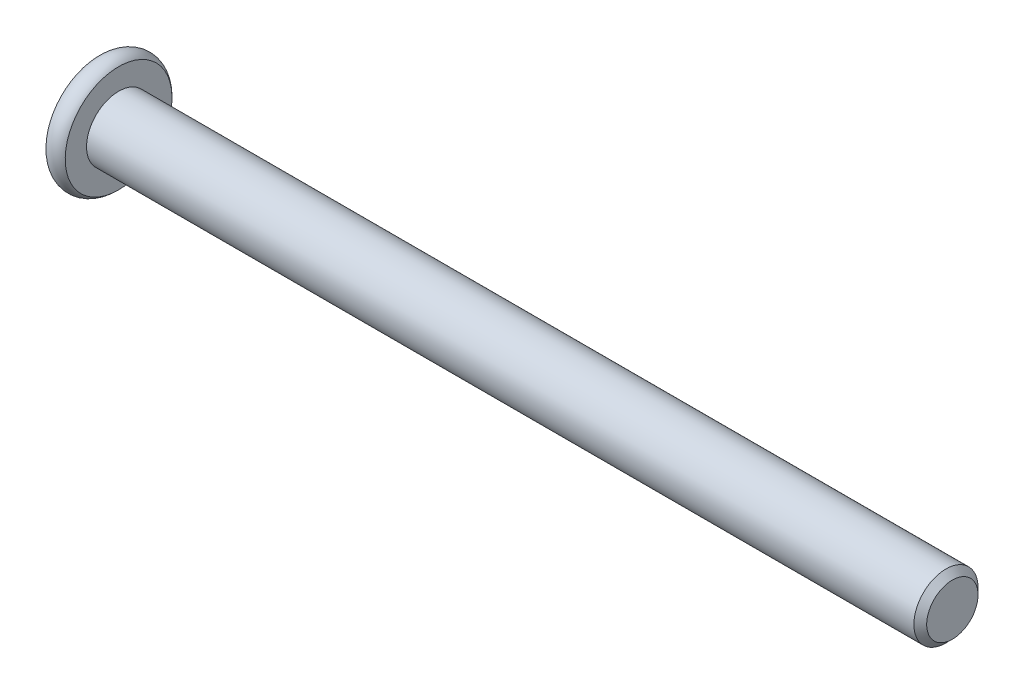
from build123d import *

# Parameters (mm, degrees)
SKETCH2_R           = 2.5
BOSS_EXTRUDE1_DEPTH = 65
CHAMFER1_SIZE       = 0.5
CUT_EXTRUDE1_DEPTH  = 2.3
SKETCH8_R           = 1.782050808
CUT_EXTRUDE2_DEPTH  = 1
CUT_EXTRUDE2_TAPER  = 45


with BuildPart() as part:
    # Sketch2 → Boss-Extrude1 (new body)
    with BuildSketch(Plane(origin=(0, 0, 0), x_dir=(0, 0, -1), z_dir=(1, 0, 0))):
        Circle(SKETCH2_R)
    extrude(amount=-BOSS_EXTRUDE1_DEPTH)

    # Chamfer1
    chamfer1_edges = [part.edges().sort_by_distance(p)[0] for p in [
        (0, 0, 2.5),
    ]]
    chamfer(chamfer1_edges, length=CHAMFER1_SIZE)

    # Sketch6 → Revolve1 (revolve)
    with BuildSketch(Plane.XY):
        with BuildLine():
            Line((-66.5, 0), (-66.5, 4.161437828))
            ThreePointArc((-66.5, 4.161437828), (-65.75, 4.5), (-65, 4.161437828))
            Line((-65, 4.161437828), (-65, 0))
            Line((-65, 0), (-66.5, 0))
        make_face()
    revolve(axis=Axis((-65, 0, 0), (1, 0, 0)))

    # Sketch7 → Cut-Extrude1 (cut)
    with BuildSketch(Plane.ZY.offset(66.5)):
        Polygon((0, 1.732050808), (-1.5, 0.866025404), (-1.5, -0.866025404), (0, -1.732050808), (1.5, -0.866025404), (1.5, 0.866025404), align=None)
    extrude(amount=-CUT_EXTRUDE1_DEPTH, mode=Mode.SUBTRACT)

    # Sketch8 → Cut-Extrude2 (cut)
    with BuildSketch(Plane.ZY.offset(66.5)):
        Circle(SKETCH8_R)
    extrude(amount=-CUT_EXTRUDE2_DEPTH, taper=CUT_EXTRUDE2_TAPER, mode=Mode.SUBTRACT)


solid = part.part
